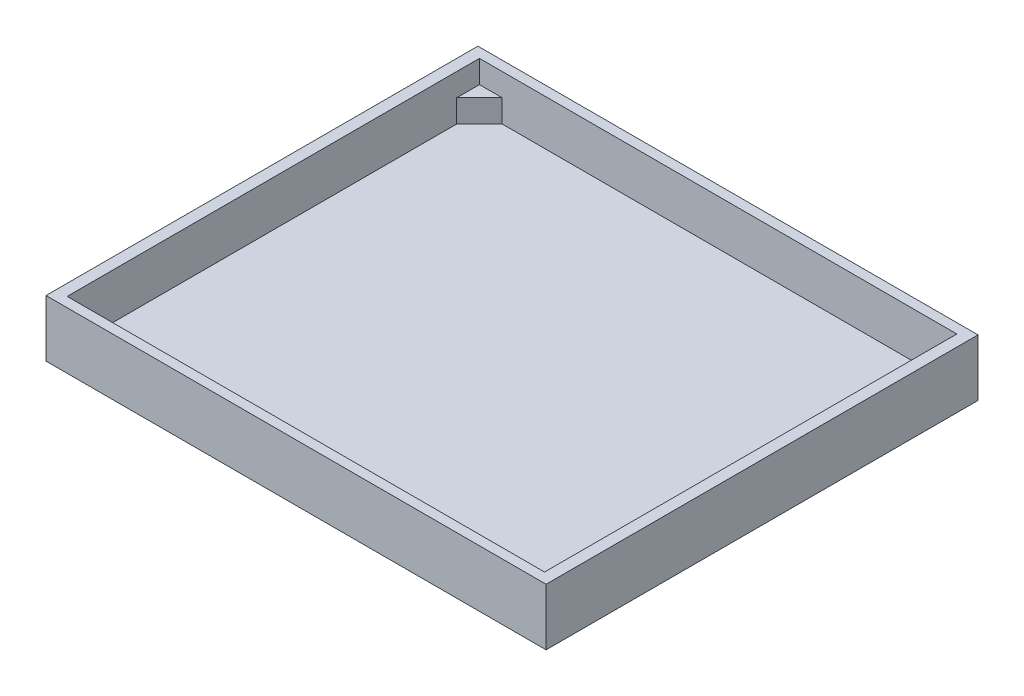
from build123d import *

# Parameters (mm, degrees)
SKETCH_1_W      = 11
SKETCH_1_H      = 9.5
EXTRUDE_1_DEPTH = 0.25
SKETCH_2_W      = 11
SKETCH_2_H      = 9.5
SKETCH_2_W_2    = 10.5
SKETCH_2_H_2    = 9.068181818
EXTRUDE_2_DEPTH = 1
EXTRUDE_3_DEPTH = 0.5


with BuildPart() as part:
    # Эскиз1 → Бобышка-Вытянуть1 (new body)
    with BuildSketch(Plane(origin=(0, 0, 0), x_dir=(1, 0, 0), z_dir=(0, 1, 0))):
        Rectangle(SKETCH_1_W, SKETCH_1_H)
    extrude(amount=EXTRUDE_1_DEPTH)

    # Эскиз2 → Бобышка-Вытянуть2 (add)
    with BuildSketch(Plane(origin=(0, 0.25, 0), x_dir=(1, 0, 0), z_dir=(0, 1, 0))):
        Rectangle(SKETCH_2_W, SKETCH_2_H)
        Rectangle(SKETCH_2_W_2, SKETCH_2_H_2, mode=Mode.SUBTRACT)
    extrude(amount=EXTRUDE_2_DEPTH)

    # Эскиз3 → Бобышка-Вытянуть3 (add)
    with BuildSketch(Plane(origin=(0, 0.25, 0), x_dir=(1, 0, 0), z_dir=(0, 1, 0))):
        Polygon((-5.25, 4.534090909), (-4.75, 4.534090909), (-5.25, 4.034090909), align=None)
        Polygon((-5.25, -4.534090909), (-5.25, -4.034090909), (-4.75, -4.534090909), align=None)
        Polygon((5.25, -4.534090909), (5.25, -4.034090909), (4.75, -4.534090909), align=None)
        Polygon((4.75, 4.534090909), (5.25, 4.034090909), (5.25, 4.534090909), align=None)
    extrude(amount=EXTRUDE_3_DEPTH)


solid = part.part
